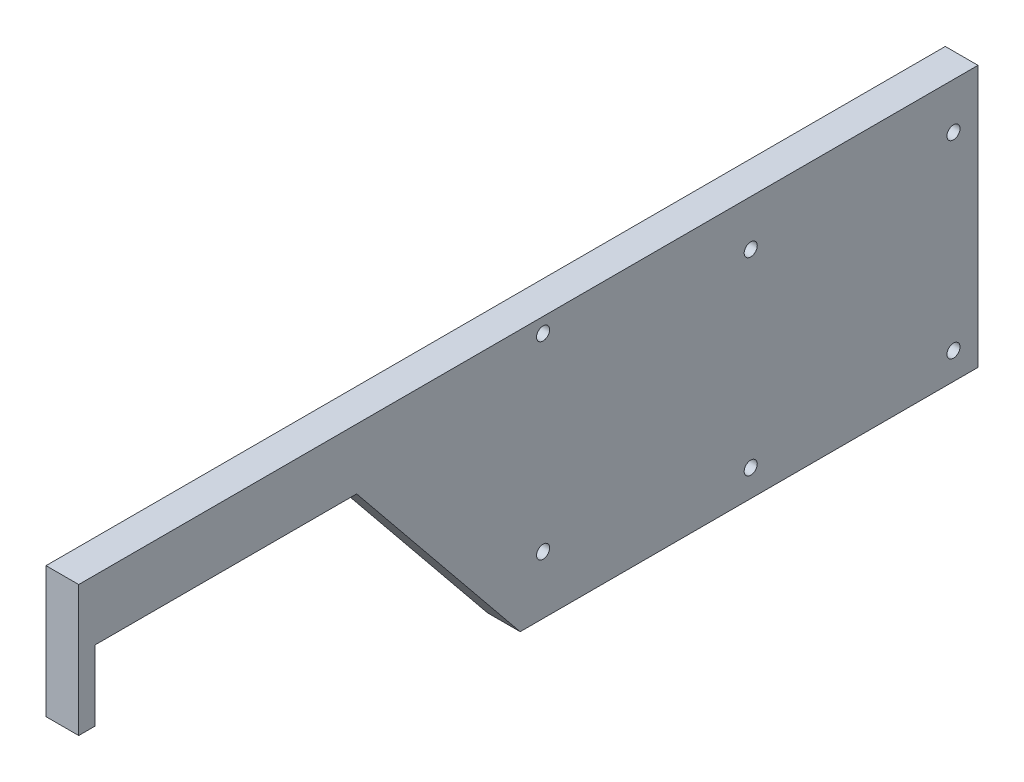
from build123d import *

# Parameters (mm, degrees)
SKETCH1_R           = 2
BOSS_EXTRUDE1_DEPTH = 10


with BuildPart() as part:
    # Sketch1 → Boss-Extrude1 (new body)
    with BuildSketch(Plane(origin=(0, 0, 0), x_dir=(0, 0, -1), z_dir=(1, 0, 0))):
        Polygon((-38, 10.75), (-38, -10.75), (-43, -10.75), (-43, 29.25), (232, 29.25), (232, -50.75), (92, -50.75), (42, 10.75), align=None)
        with Locations((99, 24.75)):
            Circle(SKETCH1_R, mode=Mode.SUBTRACT)
        with Locations((99, -33.05)):
            Circle(SKETCH1_R, mode=Mode.SUBTRACT)
        with Locations((162.5, 15.25)):
            Circle(SKETCH1_R, mode=Mode.SUBTRACT)
        with Locations((224.5, 15.25)):
            Circle(SKETCH1_R, mode=Mode.SUBTRACT)
        with Locations((162.5, -42.55)):
            Circle(SKETCH1_R, mode=Mode.SUBTRACT)
        with Locations((224.5, -42.55)):
            Circle(SKETCH1_R, mode=Mode.SUBTRACT)
    extrude(amount=BOSS_EXTRUDE1_DEPTH)


solid = part.part
